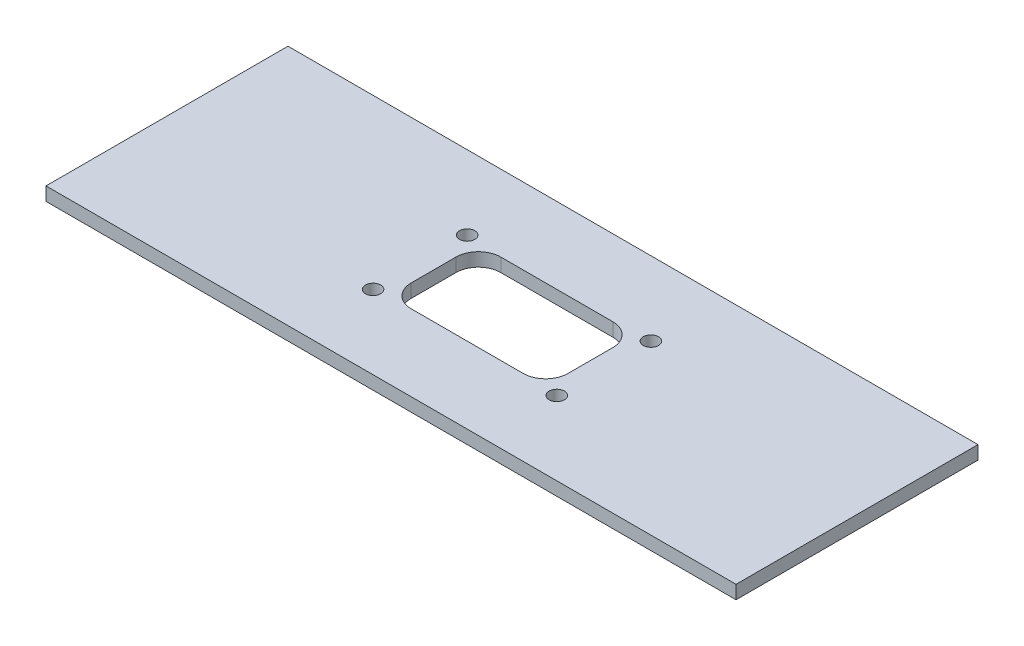
from build123d import *

# Parameters (mm, degrees)
SKETCH1_W           = 308
SKETCH1_H           = 108
BOSS_EXTRUDE1_DEPTH = 6
CUT_EXTRUDE1_DEPTH  = 10
SKETCH3_R           = 3.4
CUT_EXTRUDE2_DEPTH  = 7


with BuildPart() as part:
    # Sketch1 → Boss-Extrude1 (new body)
    with BuildSketch(Plane(origin=(0, 0, 0), x_dir=(1, 0, 0), z_dir=(0, 1, 0))):
        Rectangle(SKETCH1_W, SKETCH1_H)
    extrude(amount=BOSS_EXTRUDE1_DEPTH)

    # Sketch2 → Cut-Extrude1 (cut)
    with BuildSketch(Plane.XZ):
        with BuildLine():
            Line((-25, -20), (25, -20))
            ThreePointArc((25, -20), (32.071067812, -17.071067812), (35, -10))
            Line((35, -10), (35, 10))
            ThreePointArc((35, 10), (32.071067812, 17.071067812), (25, 20))
            Line((25, 20), (-25, 20))
            ThreePointArc((-25, 20), (-32.071067812, 17.071067812), (-35, 10))
            Line((-35, 10), (-35, -10))
            ThreePointArc((-35, -10), (-32.071067812, -17.071067812), (-25, -20))
        make_face()
    extrude(amount=-CUT_EXTRUDE1_DEPTH, mode=Mode.SUBTRACT)

    # Sketch3 → Cut-Extrude2 (cut, through all)
    with BuildSketch(Plane(origin=(0, 0, 0), x_dir=(-1, 0, 0), z_dir=(0, -1, 0))):
        with Locations((41, -21)):
            Circle(SKETCH3_R)
        with Locations((-41, -21)):
            Circle(SKETCH3_R)
        with Locations((-41, 21)):
            Circle(SKETCH3_R)
        with Locations((41, 21)):
            Circle(SKETCH3_R)
    extrude(amount=-CUT_EXTRUDE2_DEPTH, mode=Mode.SUBTRACT)


solid = part.part
